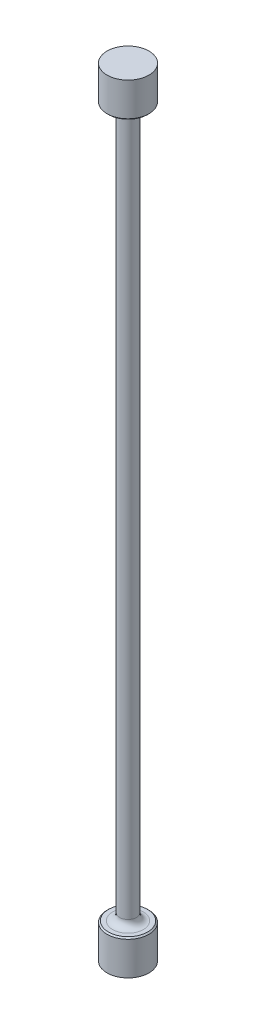
from build123d import *

# Parameters (mm, degrees)
FILLET1_R     = 2
CHAMFER1_SIZE = 0.381


with BuildPart() as part:
    # Sketch1 → Revolve1 (revolve)
    with BuildSketch(Plane.XY, mode=Mode.PRIVATE) as revolve1_sk:
        Polygon((0, -111.618928003), (0, 111.618928003), (6, 111.618928003), (6, 101.618928003), (2.4, 101.618928003), (2.4, -101.618928003), (6, -101.618928003), (6, -111.618928003), align=None)
    revolve(revolve1_sk.sketch.rotate(Axis((0, 0, 0), (0, 1, 0)), 90), axis=Axis((0, 0, 0), (0, 1, 0)))  # turned: the seam where the file's is

    # Fillet1
    fillet1_edges = [part.edges().sort_by_distance(p)[0] for p in [
        (0, 101.618928003, 2.4),
        (0, -101.618928003, 2.4),
    ]]
    fillet(fillet1_edges, radius=FILLET1_R)

    # Chamfer1
    chamfer1_edges = [part.edges().sort_by_distance(p)[0] for p in [
        (0, -101.618928003, 6),
        (0, 101.618928003, 6),
    ]]
    chamfer(chamfer1_edges, length=CHAMFER1_SIZE)


solid = part.part
